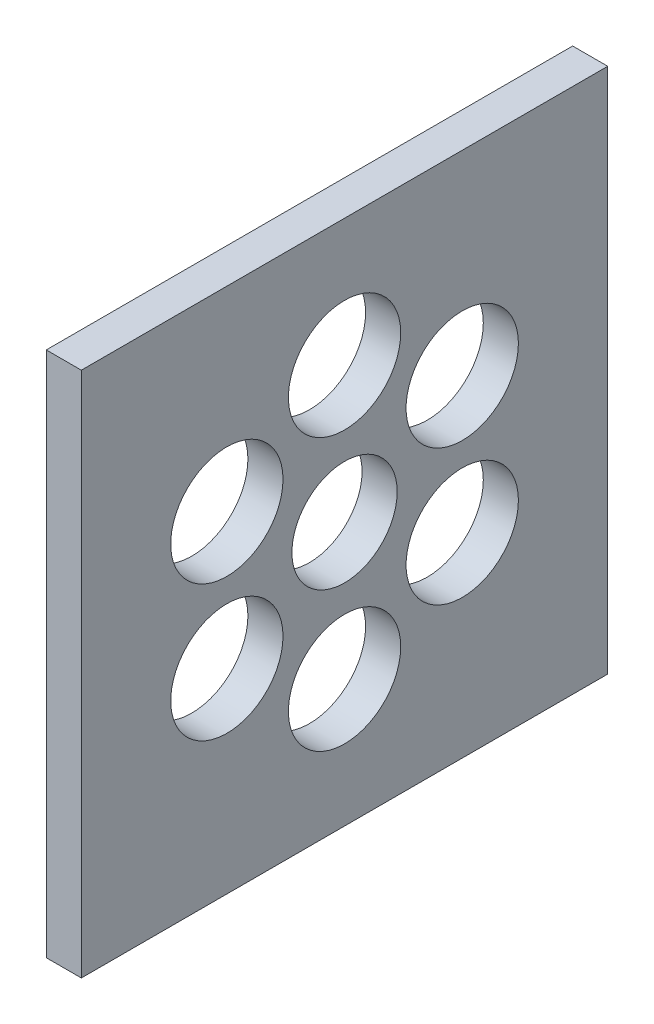
from build123d import *

# Parameters (mm, degrees)
SKETCH1_W           = 150
SKETCH1_H           = 150
BOSS_EXTRUDE1_DEPTH = 10
SKETCH2_R           = 15
SKETCH2_R_2         = 16
CUT_EXTRUDE1_DEPTH  = 25


with BuildPart() as part:
    # Sketch1 → Boss-Extrude1 (new body)
    with BuildSketch(Plane(origin=(0, 0, 0), x_dir=(0, 0, -1), z_dir=(1, 0, 0))):
        Rectangle(SKETCH1_W, SKETCH1_H)
    extrude(amount=BOSS_EXTRUDE1_DEPTH)

    # Sketch2 → Cut-Extrude1 (cut)
    with BuildSketch(Plane(origin=(10, 0, 0), x_dir=(0, 0, -1), z_dir=(1, 0, 0))):
        Circle(SKETCH2_R)
        with Locations((0, 38.727703316)):
            Circle(SKETCH2_R_2)
        with Locations((33.539174902, 19.363851658)):
            Circle(SKETCH2_R_2)
        with Locations((33.539174902, -19.363851658)):
            Circle(SKETCH2_R_2)
        with Locations((0, -38.727703316)):
            Circle(SKETCH2_R_2)
        with Locations((-33.539174902, -19.363851658)):
            Circle(SKETCH2_R_2)
        with Locations((-33.539174902, 19.363851658)):
            Circle(SKETCH2_R_2)
    extrude(amount=-CUT_EXTRUDE1_DEPTH, mode=Mode.SUBTRACT)


solid = part.part
